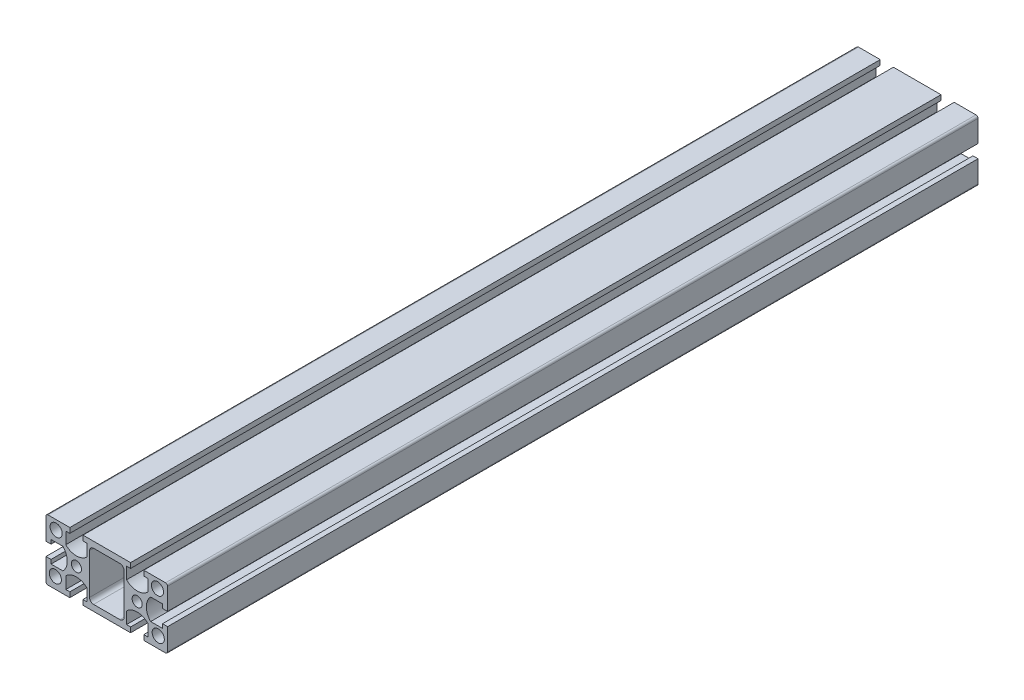
from build123d import *

# Parameters (mm, degrees)
MODEL_R             = 2.5
MODEL_R_2           = 3
BOSS_EXTRUDE1_DEPTH = 400


with BuildPart() as part:
    # Model → Boss-Extrude1 (new body)
    with BuildSketch(Plane.XY):
        with BuildLine():
            Line((-27.5, 3.25), (-30, 3.25))
            Line((-30, 3.25), (-30, 14))
            ThreePointArc((-30, 14), (-29.707106781, 14.707106781), (-29, 15))
            Line((-29, 15), (-18.25, 15))
            Line((-18.25, 15), (-18.25, 12.5))
            Line((-18.25, 12.5), (-20.25, 12.5))
            Line((-20.25, 12.5), (-20.25, 6.643928679))
            ThreePointArc((-20.25, 6.643928679), (-15, 4.5), (-9.75, 6.643928679))
            Line((-9.75, 6.643928679), (-9.75, 12.5))
            Line((-9.75, 12.5), (-11.75, 12.5))
            Line((-11.75, 12.5), (-11.75, 15))
            Line((-11.75, 15), (11.75, 15))
            Line((11.75, 15), (11.75, 12.5))
            Line((11.75, 12.5), (9.75, 12.5))
            Line((9.75, 12.5), (9.75, 6.643928679))
            ThreePointArc((9.75, 6.643928679), (15, 4.5), (20.25, 6.643928679))
            Line((20.25, 6.643928679), (20.25, 12.5))
            Line((20.25, 12.5), (18.25, 12.5))
            Line((18.25, 12.5), (18.25, 15))
            Line((18.25, 15), (29, 15))
            ThreePointArc((29, 15), (29.707106781, 14.707106781), (30, 14))
            Line((30, 14), (30, 3.25))
            Line((30, 3.25), (27.5, 3.25))
            Line((27.5, 3.25), (27.5, 5.25))
            Line((27.5, 5.25), (21.643928679, 5.25))
            ThreePointArc((21.643928679, 5.25), (19.5, 0), (21.643928679, -5.25))
            Line((21.643928679, -5.25), (27.5, -5.25))
            Line((27.5, -5.25), (27.5, -3.25))
            Line((27.5, -3.25), (30, -3.25))
            Line((30, -3.25), (30, -14))
            ThreePointArc((30, -14), (29.707106781, -14.707106781), (29, -15))
            Line((29, -15), (18.25, -15))
            Line((18.25, -15), (18.25, -12.5))
            Line((18.25, -12.5), (20.25, -12.5))
            Line((20.25, -12.5), (20.25, -6.643928679))
            ThreePointArc((20.25, -6.643928679), (15, -4.5), (9.75, -6.643928679))
            Line((9.75, -6.643928679), (9.75, -12.5))
            Line((9.75, -12.5), (11.75, -12.5))
            Line((11.75, -12.5), (11.75, -15))
            Line((11.75, -15), (-11.75, -15))
            Line((-11.75, -15), (-11.75, -12.5))
            Line((-11.75, -12.5), (-9.75, -12.5))
            Line((-9.75, -12.5), (-9.75, -6.643928679))
            ThreePointArc((-9.75, -6.643928679), (-15, -4.5), (-20.25, -6.643928679))
            Line((-20.25, -6.643928679), (-20.25, -12.5))
            Line((-20.25, -12.5), (-18.25, -12.5))
            Line((-18.25, -12.5), (-18.25, -15))
            Line((-18.25, -15), (-29, -15))
            ThreePointArc((-29, -15), (-29.707106781, -14.707106781), (-30, -14))
            Line((-30, -14), (-30, -3.25))
            Line((-30, -3.25), (-27.5, -3.25))
            Line((-27.5, -3.25), (-27.5, -5.25))
            Line((-27.5, -5.25), (-21.643928679, -5.25))
            ThreePointArc((-21.643928679, -5.25), (-19.5, 0), (-21.643928679, 5.25))
            Line((-21.643928679, 5.25), (-27.5, 5.25))
            Line((-27.5, 5.25), (-27.5, 3.25))
        make_face()
        with Locations((-15, 0)):
            Circle(MODEL_R, mode=Mode.SUBTRACT)
        with Locations((-25, 10.531430074)):
            Circle(MODEL_R_2, mode=Mode.SUBTRACT)
        with Locations((-25.399251578, -9.468569926)):
            Circle(MODEL_R_2, mode=Mode.SUBTRACT)
        with Locations((25.399251578, -9.468569926)):
            Circle(MODEL_R_2, mode=Mode.SUBTRACT)
        with Locations((15, 0)):
            Circle(MODEL_R, mode=Mode.SUBTRACT)
        with Locations((25, 10.531430074)):
            Circle(MODEL_R_2, mode=Mode.SUBTRACT)
        with BuildLine():
            Line((6.5, 12), (-6.5, 12))
            ThreePointArc((-6.5, 12), (-7.914213562, 11.414213562), (-8.5, 10))
            Line((-8.5, 10), (-8.5, -10))
            ThreePointArc((-8.5, -10), (-7.914213562, -11.414213562), (-6.5, -12))
            Line((-6.5, -12), (6.5, -12))
            ThreePointArc((6.5, -12), (7.914213562, -11.414213562), (8.5, -10))
            Line((8.5, -10), (8.5, 10))
            ThreePointArc((8.5, 10), (7.914213562, 11.414213562), (6.5, 12))
        make_face(mode=Mode.SUBTRACT)
    extrude(amount=BOSS_EXTRUDE1_DEPTH)


solid = part.part
